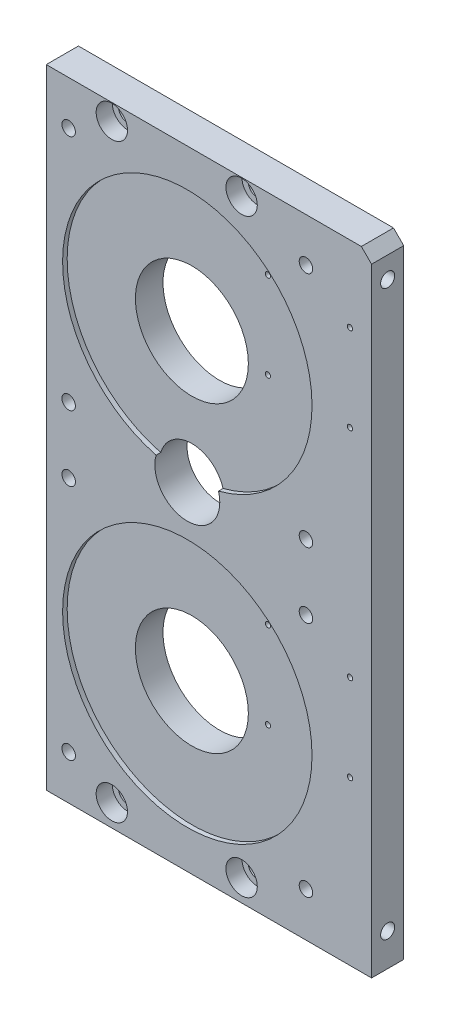
from build123d import *

# Parameters (mm, degrees)
SKETCH1_W           = 95.41
SKETCH1_H           = 184.3
SKETCH1_R           = 16.565
BOSS_EXTRUDE1_DEPTH = 9.43
CHAMFER1_SIZE       = 3
SKETCH2_R           = 36.575
CUT_EXTRUDE1_DEPTH  = 1.34
SKETCH3_R           = 9.525
CUT_EXTRUDE2_DEPTH  = 10.43
SKETCH4_R           = 2.8
CUT_EXTRUDE3_DEPTH  = 10.43
SKETCH5_R           = 4.6
CUT_EXTRUDE4_DEPTH  = 4.72
SKETCH6_R           = 1.98
CUT_EXTRUDE5_DEPTH  = 10.43
SKETCH7_R           = 2.06
CUT_EXTRUDE6_DEPTH  = 6.93
SKETCH9_R           = 0.77
CUT_EXTRUDE7_DEPTH  = 10.43


with BuildPart() as part:
    # Sketch1 → Boss-Extrude1 (new body)
    with BuildSketch(Plane.XY):
        with Locations((47.705, 92.15)):
            Rectangle(SKETCH1_W, SKETCH1_H)
        with Locations((41.365, 136.635)):
            Circle(SKETCH1_R, mode=Mode.SUBTRACT)
        with Locations((41.365, 47.785)):
            Circle(SKETCH1_R, mode=Mode.SUBTRACT)
    extrude(amount=BOSS_EXTRUDE1_DEPTH)

    # Chamfer1
    chamfer1_edges = [part.edges().sort_by_distance(p)[0] for p in [
        (95.41, 184.3, 4.715),
    ]]
    chamfer(chamfer1_edges, length=CHAMFER1_SIZE)

    # Sketch2 → Cut-Extrude1 (cut)
    with BuildSketch(Plane.XY.offset(9.43)):
        with Locations((41.365, 136.635)):
            Circle(SKETCH2_R)
        with Locations((41.365, 47.785)):
            Circle(SKETCH2_R)
    extrude(amount=-CUT_EXTRUDE1_DEPTH, mode=Mode.SUBTRACT)

    # Sketch3 → Cut-Extrude2 (cut, through all)
    with BuildSketch(Plane.XY.offset(9.43)):
        with Locations((41.365, 98.535)):
            Circle(SKETCH3_R)
    extrude(amount=-CUT_EXTRUDE2_DEPTH, mode=Mode.SUBTRACT)

    # Sketch4 → Cut-Extrude3 (cut, through all)
    with BuildSketch(Plane.XY.offset(9.43)):
        with Locations((19.23, 179.5)):
            Circle(SKETCH4_R)
        with Locations((57.29, 179.5)):
            Circle(SKETCH4_R)
        with Locations((19.23, 6.44)):
            Circle(SKETCH4_R)
        with Locations((57.29, 6.44)):
            Circle(SKETCH4_R)
    extrude(amount=-CUT_EXTRUDE3_DEPTH, mode=Mode.SUBTRACT)

    # Sketch5 → Cut-Extrude4 (cut)
    with BuildSketch(Plane.XY.offset(9.43)):
        with Locations((19.23, 179.5)):
            Circle(SKETCH5_R)
        with Locations((57.29, 179.5)):
            Circle(SKETCH5_R)
        with Locations((19.23, 6.44)):
            Circle(SKETCH5_R)
        with Locations((57.29, 6.44)):
            Circle(SKETCH5_R)
    extrude(amount=-CUT_EXTRUDE4_DEPTH, mode=Mode.SUBTRACT)

    # Sketch6 → Cut-Extrude5 (cut, through all)
    with BuildSketch(Plane.XY.offset(9.43)):
        with Locations((6.567, 171.433)):
            Circle(SKETCH6_R)
        with Locations((76.163, 171.433)):
            Circle(SKETCH6_R)
        with Locations((76.163, 101.837)):
            Circle(SKETCH6_R)
        with Locations((6.567, 101.837)):
            Circle(SKETCH6_R)
        with Locations((6.567, 82.583)):
            Circle(SKETCH6_R)
        with Locations((76.163, 82.583)):
            Circle(SKETCH6_R)
        with Locations((76.163, 12.987)):
            Circle(SKETCH6_R)
        with Locations((6.567, 12.987)):
            Circle(SKETCH6_R)
    extrude(amount=-CUT_EXTRUDE5_DEPTH, mode=Mode.SUBTRACT)

    # Sketch7 → Cut-Extrude6 (cut)
    with BuildSketch(Plane(origin=(95.41, 0, 0), x_dir=(0, 0, -1), z_dir=(1, 0, 0))):
        with Locations((-4.715, 175.02)):
            Circle(SKETCH7_R)
        with Locations((-4.715, 9.6)):
            Circle(SKETCH7_R)
    extrude(amount=-CUT_EXTRUDE6_DEPTH, mode=Mode.SUBTRACT)

    # Sketch9 → Cut-Extrude7 (cut, through all)
    with BuildSketch(Plane(origin=(0, 0, 0), x_dir=(-1, 0, 0), z_dir=(0, 0, -1))):
        with Locations((-89.08, 162.035)):
            Circle(SKETCH9_R)
        with Locations((-63.68, 162.035)):
            Circle(SKETCH9_R)
        with Locations((-89.08, 136.635)):
            Circle(SKETCH9_R)
        with Locations((-63.68, 136.635)):
            Circle(SKETCH9_R)
        with Locations((-89.08, 73.185)):
            Circle(SKETCH9_R)
        with Locations((-63.68, 73.185)):
            Circle(SKETCH9_R)
        with Locations((-89.08, 47.785)):
            Circle(SKETCH9_R)
        with Locations((-63.68, 47.785)):
            Circle(SKETCH9_R)
    extrude(amount=-CUT_EXTRUDE7_DEPTH, mode=Mode.SUBTRACT)


solid = part.part
